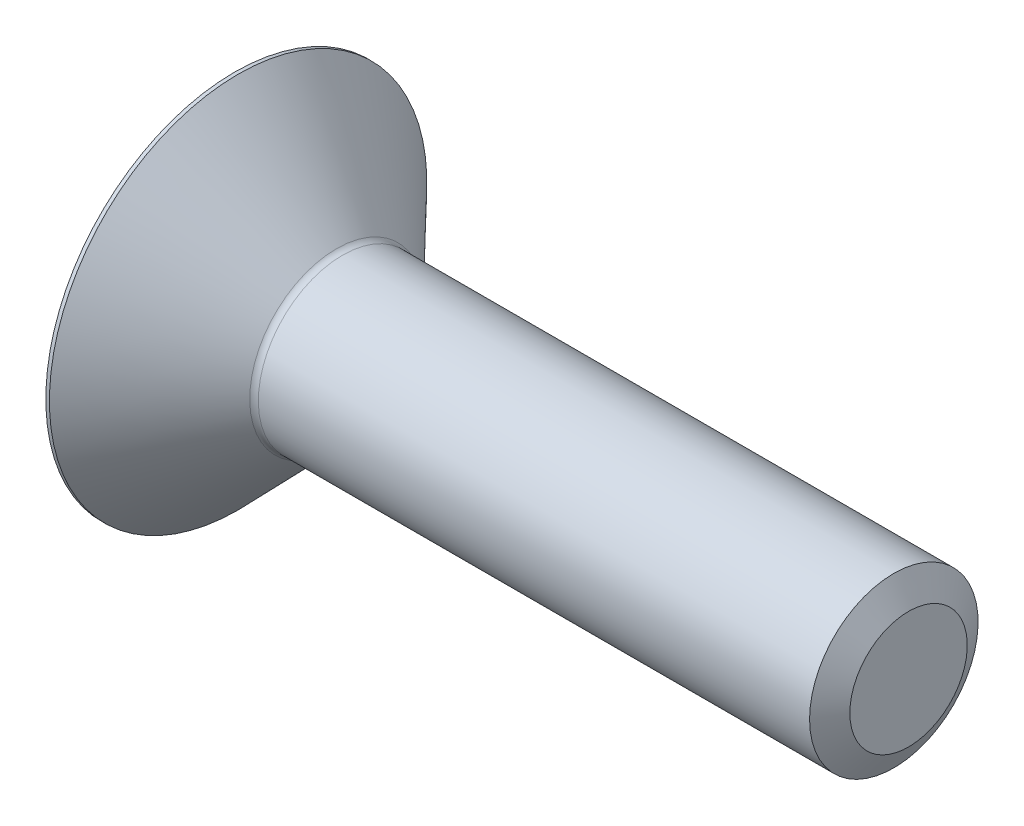
from build123d import *

# Parameters (mm, degrees)
CUT_EXTRUDE_1_DEPTH = 2.58


with BuildPart() as part:
    # Sketch 1 → Revolve 1 (revolve)
    with BuildSketch(Plane.XY):
        with BuildLine():
            Line((0, 2), (-13.435105037, 2))
            ThreePointArc((-13.435105037, 2), (-13.513251262, 2.015899029), (-13.578972997, 2.061068326))
            Line((-13.578972997, 2.061068326), (-15.914908162, 4.48))
            Line((-15.914908162, 4.48), (-16, 4.48))
            Line((-16, 4.48), (-16, 0))
            Line((-16, 0), (0, 0))
            Line((0, 0), (0, 2))
        make_face()
    revolve(axis=Axis((0, 0, 0), (-1, 0, 0)))

    # Sketch 2 → Cut-Extrude 1 (cut)
    with BuildSketch(Plane.ZY.offset(16)):
        Polygon((0, 1.443375673), (-1.25, 0.721687836), (-1.25, -0.721687836), (0, -1.443375673), (1.25, -0.721687836), (1.25, 0.721687836), align=None)
    extrude(amount=-CUT_EXTRUDE_1_DEPTH, mode=Mode.SUBTRACT)

    # Sketch 6 → Revolve 2 (revolve)
    with BuildSketch(Plane.XY):
        Polygon((-14.5, 1.443375673), (-13.666666667, 0), (-13.05, 0), (-13.05, 1.443375673), align=None)
    revolve(axis=Axis((-16, 0, 0), (1, 0, 0)))

    # Sketch 7 → Cut-Revolve 2 (revolve, cut)
    with BuildSketch(Plane.XY):
        Polygon((-16, 1.443375673), (-16, 0), (-15.593, 0), align=None)
    revolve(axis=Axis((-16, 0, 0), (1, 0, 0)), mode=Mode.SUBTRACT)

    # Sketch 4 → Cut-Revolve 1 (revolve, cut)
    with BuildSketch(Plane.XY):
        Polygon((-0.35, 2), (0, 1.393782217), (0.35, 2), align=None)
    revolve(axis=Axis((-0.35, 0, 0), (1, 0, 0)), mode=Mode.SUBTRACT)


solid = part.part
